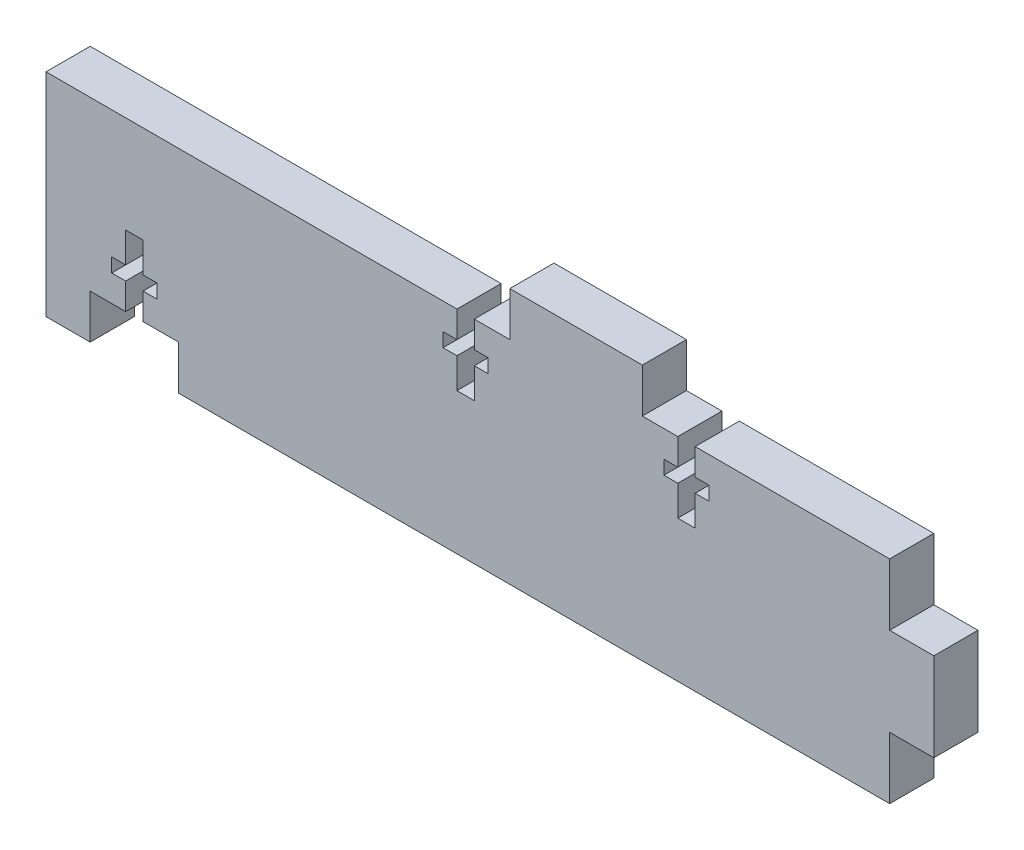
from build123d import *

# Parameters (mm, degrees)
BOSS_EXTRUDE1_DEPTH = 6.35
SKETCH2_W           = 12.7
SKETCH2_H           = 6.35
CUT_EXTRUDE1_DEPTH  = 7.35
CUT_EXTRUDE5_DEPTH  = 7.35


with BuildPart() as part:
    # Sketch1 → Boss-Extrude1 (new body)
    with BuildSketch(Plane.XY):
        Polygon((66.675, 30.48), (0, 30.48), (0, 0), (121.285, 0), (121.285, 8.89), (127.635, 8.89), (127.635, 21.59), (121.285, 21.59), (121.285, 30.48), (85.725, 30.48), (85.725, 36.83), (66.675, 36.83), align=None)
    extrude(amount=BOSS_EXTRUDE1_DEPTH)

    # Sketch2 → Cut-Extrude1 (cut, through all)
    with BuildSketch(Plane.XY.offset(6.35)):
        with Locations((12.7, 3.175)):
            Rectangle(SKETCH2_W, SKETCH2_H)
    extrude(amount=-CUT_EXTRUDE1_DEPTH, mode=Mode.SUBTRACT)

    # Sketch5 → Cut-Extrude5 (cut, through all)
    with BuildSketch(Plane.XY.offset(6.35)):
        Polygon((61.575, 30.48), (59.075, 30.48), (59.075, 26.67), (57.075, 26.67), (57.075, 24.67), (59.075, 24.67), (59.075, 20.32), (61.575, 20.32), (61.575, 24.67), (63.575, 24.67), (63.575, 26.67), (61.575, 26.67), align=None)
        Polygon((90.825, 26.67), (88.825, 26.67), (88.825, 24.67), (90.825, 24.67), (90.825, 20.32), (93.325, 20.32), (93.325, 24.67), (95.325, 24.67), (95.325, 26.67), (93.325, 26.67), (93.325, 30.48), (90.825, 30.48), align=None)
        Polygon((11.45, 10.16), (11.45, 6.35), (13.95, 6.35), (13.95, 10.16), (15.95, 10.16), (15.95, 12.16), (13.95, 12.16), (13.95, 16.51), (11.45, 16.51), (11.45, 12.16), (9.45, 12.16), (9.45, 10.16), align=None)
    extrude(amount=-CUT_EXTRUDE5_DEPTH, mode=Mode.SUBTRACT)


solid = part.part
